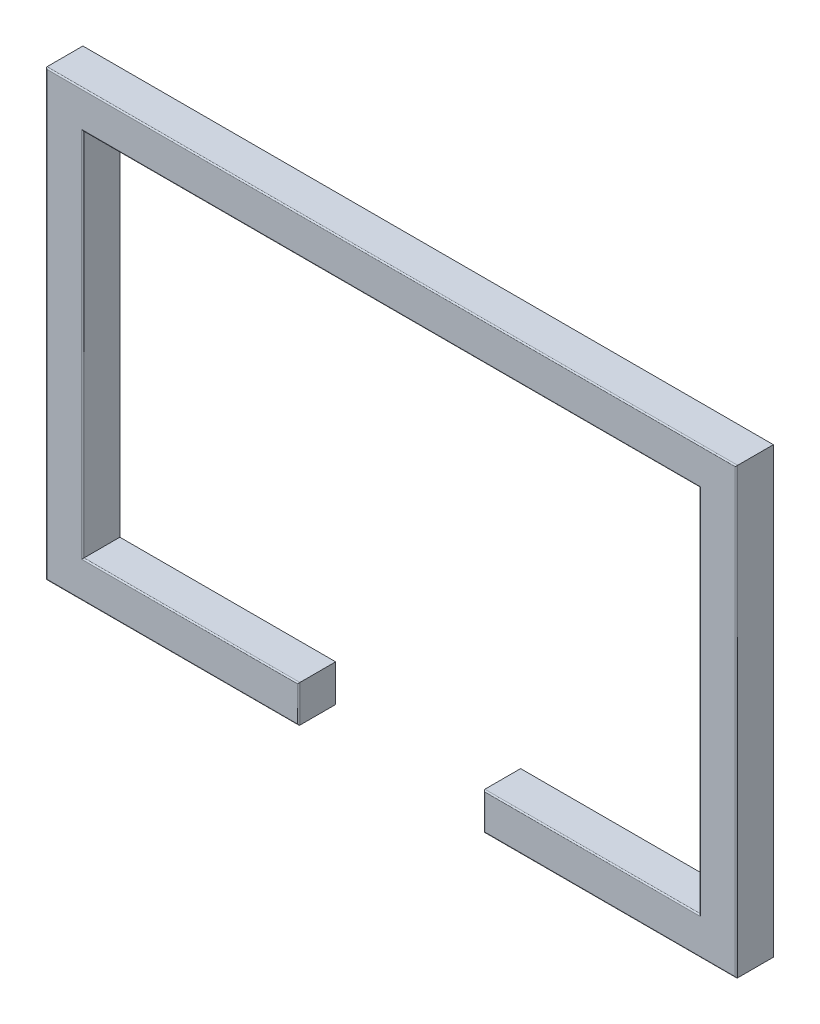
from build123d import *

# Parameters (mm, degrees)
SALIENTE_EXTRUIR1_DEPTH = 30
REDONDEO1_R             = 1


with BuildPart() as part:
    # Croquis1 → Saliente-Extruir1 (new body)
    with BuildSketch(Plane.XY):
        Polygon((-280, 180), (280, 180), (280, -180), (75, -180), (75, -150), (250, -150), (250, 150), (-250, 150), (-250, -150), (-75, -150), (-75, -180), (-280, -180), align=None)
    extrude(amount=SALIENTE_EXTRUIR1_DEPTH)

    # Redondeo1
    redondeo1_edges = [part.edges().sort_by_distance(p)[0] for p in [
        (177.5, -180, 30),
        (280, 0, 30),
        (0, 180, 30),
        (-280, 0, 30),
        (-177.5, -180, 30),
        (-75, -165, 30),
        (-162.5, -150, 30),
        (-250, 0, 30),
        (0, 150, 30),
        (250, 0, 30),
        (162.5, -150, 30),
        (75, -165, 30),
    ]]
    fillet(redondeo1_edges, radius=REDONDEO1_R)


solid = part.part
